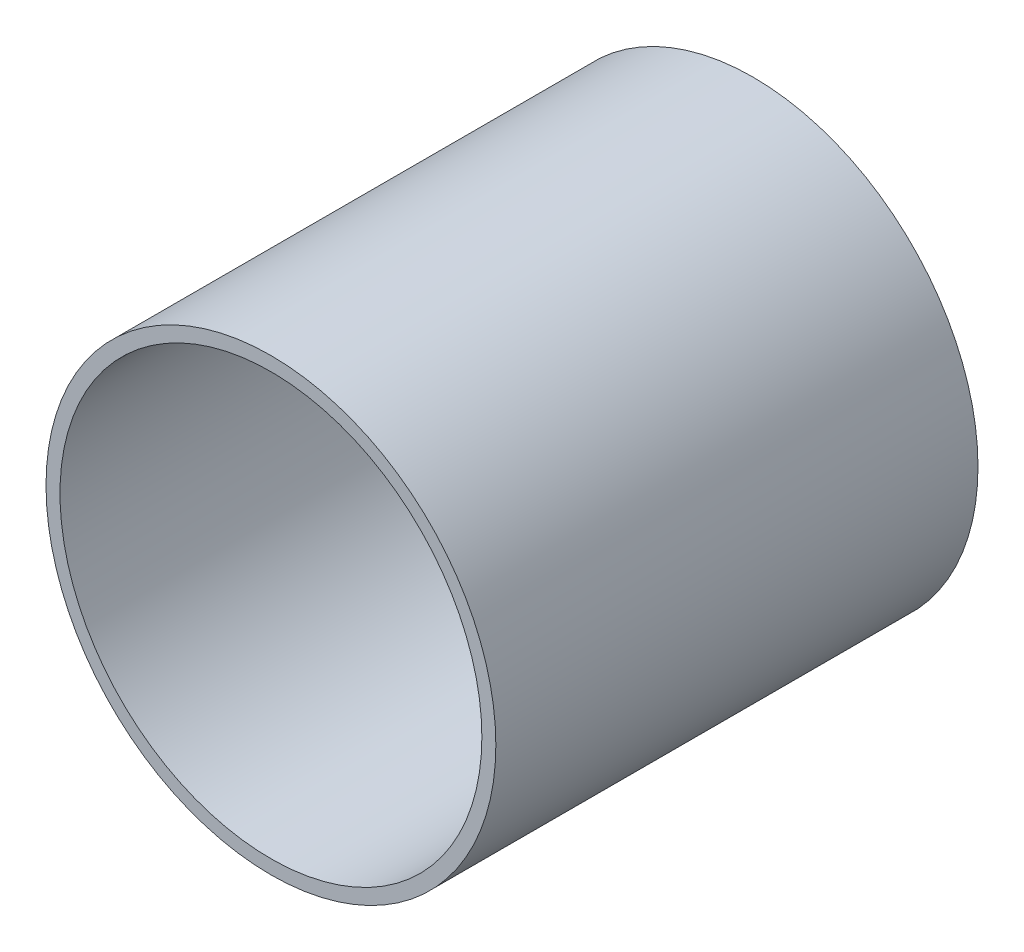
from build123d import *

# Parameters (mm, degrees)
SKETCH1_R           = 23.6982
SKETCH1_R_2         = 22.225
BOSS_EXTRUDE1_DEPTH = 50.8


with BuildPart() as part:
    # Sketch1 → Boss-Extrude1 (new body)
    with BuildSketch(Plane.XY):
        Circle(SKETCH1_R)
        Circle(SKETCH1_R_2, mode=Mode.SUBTRACT)
    extrude(amount=BOSS_EXTRUDE1_DEPTH)


solid = part.part
